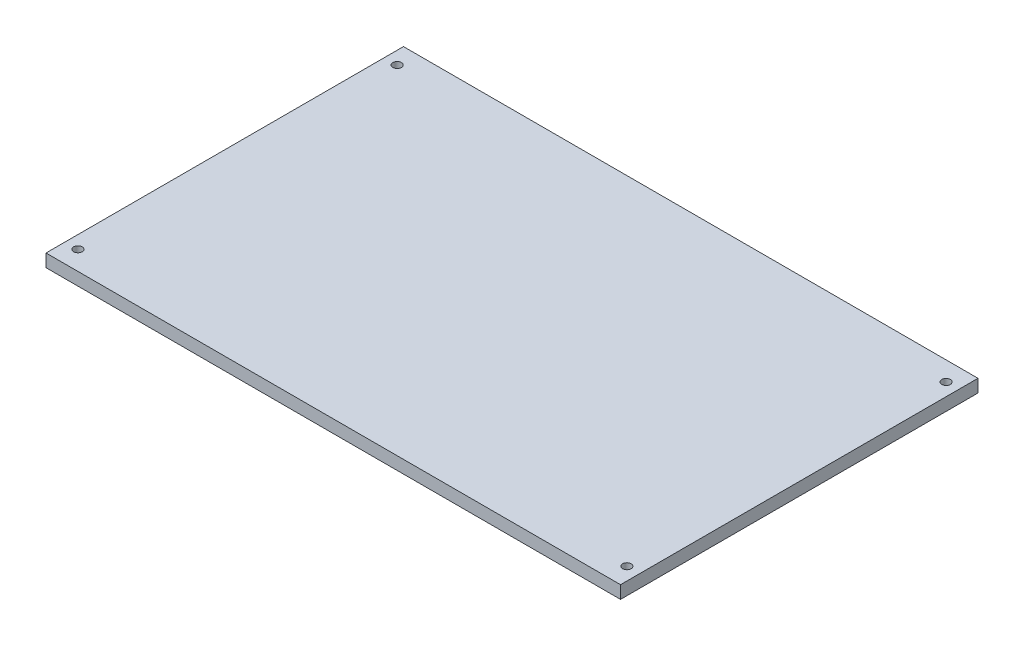
from build123d import *

# Parameters (mm, degrees)
SKETCH1_W                                = 900
SKETCH1_H                                = 560
BOSS_EXTRUDE1_DEPTH                      = 20
CBORE_FOR_1_2_HEAVY_HEX_BOLT1_AT_2_COUNT = 2
CBORE_FOR_1_2_HEAVY_HEX_BOLT1_AT_2_PITCH = 860
CBORE_FOR_1_2_HEAVY_HEX_BOLT1_AT_3_COUNT = 2
CBORE_FOR_1_2_HEAVY_HEX_BOLT1_AT_3_PITCH = 994.786409236
CBORE_FOR_1_2_HEAVY_HEX_BOLT1_AT_4_COUNT = 2
CBORE_FOR_1_2_HEAVY_HEX_BOLT1_AT_4_PITCH = 500


with BuildPart() as part:
    # Sketch1 → Boss-Extrude1 (new body)
    with BuildSketch(Plane(origin=(0, 0, 0), x_dir=(1, 0, 0), z_dir=(0, 1, 0))):
        with Locations((430, 227.887771015)):
            Rectangle(SKETCH1_W, SKETCH1_H)
    extrude(amount=BOSS_EXTRUDE1_DEPTH)

    # Sketch3 → CBORE for 1/2 Heavy Hex Bolt1 (revolve, cut)
    with BuildSketch(Plane(origin=(0, 0, -477.887771015), x_dir=(0, 0, -1), z_dir=(1, 0, 0))):
        Polygon((0, 0), (0, 20), (6.74624, 20), (6.74624, 9.2456), (14.2875, 9.2456), (14.2875, 0.635), (14.9225, 0), align=None)
    cbore_for_1_2_heavy_hex_bolt1 = revolve(axis=Axis((0, -6.35, -477.887771015), (0, 1, 0)), mode=Mode.SUBTRACT)

    # CBORE for 1/2 Heavy Hex Bolt1 at 2: CBORE for 1/2 Heavy Hex Bolt1 ×2
    with Locations(*[(i * CBORE_FOR_1_2_HEAVY_HEX_BOLT1_AT_2_PITCH, 0, 0) for i in range(1, CBORE_FOR_1_2_HEAVY_HEX_BOLT1_AT_2_COUNT)]):
        add(cbore_for_1_2_heavy_hex_bolt1, mode=Mode.SUBTRACT)

    # CBORE for 1/2 Heavy Hex Bolt1 at 3: CBORE for 1/2 Heavy Hex Bolt1 ×2
    with Locations(*[Vector(0.864507187, 0, 0.502620457) * (i * CBORE_FOR_1_2_HEAVY_HEX_BOLT1_AT_3_PITCH) for i in range(1, CBORE_FOR_1_2_HEAVY_HEX_BOLT1_AT_3_COUNT)]):
        add(cbore_for_1_2_heavy_hex_bolt1, mode=Mode.SUBTRACT)

    # CBORE for 1/2 Heavy Hex Bolt1 at 4: CBORE for 1/2 Heavy Hex Bolt1 ×2
    with Locations(*[(0, 0, i * CBORE_FOR_1_2_HEAVY_HEX_BOLT1_AT_4_PITCH) for i in range(1, CBORE_FOR_1_2_HEAVY_HEX_BOLT1_AT_4_COUNT)]):
        add(cbore_for_1_2_heavy_hex_bolt1, mode=Mode.SUBTRACT)


solid = part.part
